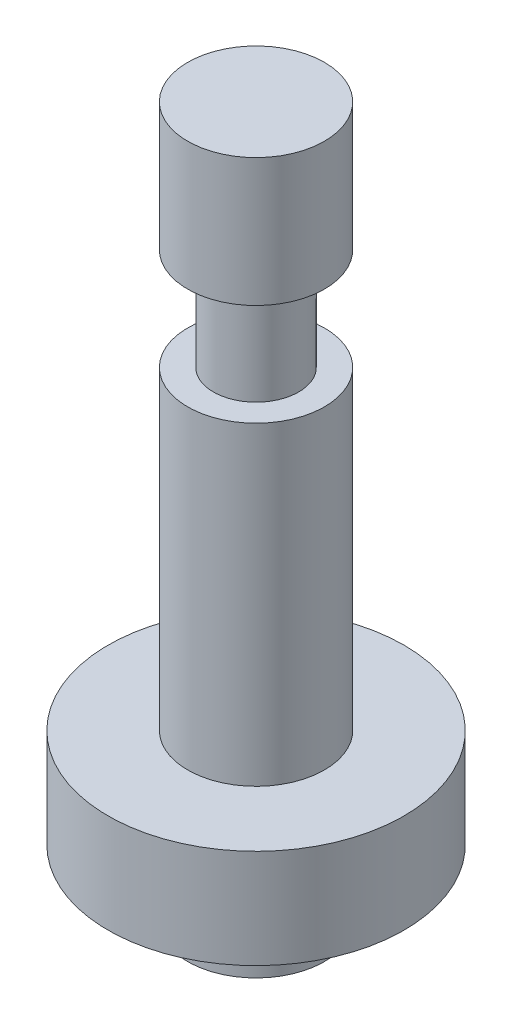
from build123d import *


with BuildPart() as part:
    # Croquis2 → Revolución1 (revolve)
    with BuildSketch(Plane(origin=(0, 0, 0), x_dir=(0, 0, -1), z_dir=(1, 0, 0))):
        Polygon((0, 65.972188438), (6.35, 65.972188438), (6.35, 54.075564294), (3.959492216, 54.075564294), (3.959492216, 44.612340542), (6.35, 44.612340542), (6.35, 15.411535824), (13.7389008, 15.411535824), (13.7389008, 6.218689894), (6.35, 6.218689894), (6.35, 0), (0, 0), align=None)
    revolve(axis=Axis((0, 0, 0), (0, 1, 0)))


solid = part.part
